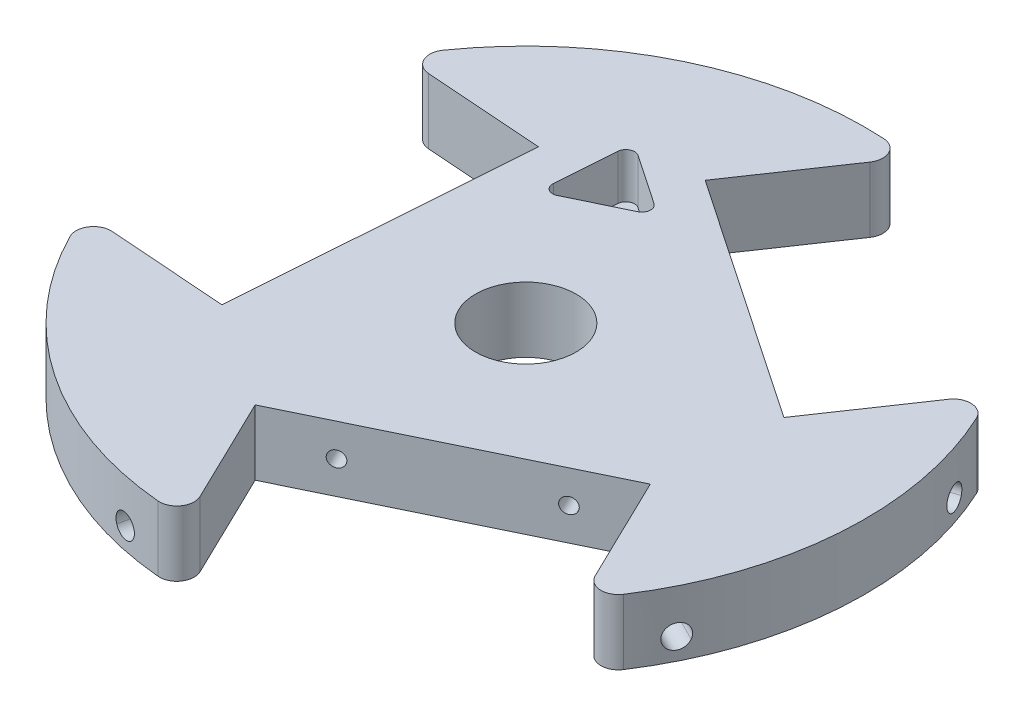
from build123d import *

# Parameters (mm, degrees)
BOSS_EXTRUDE1_DEPTH       = 9.525
F_5_8_18_TAPPED_HOLE1_D   = 14.68374
FILLET1_R                 = 2.54
F_4_40_TAPPED_HOLE1_D     = 2.2606
F_4_40_TAPPED_HOLE1_DEPTH = 6.35
F_4_40_TAPPED_HOLE1_TIP   = 0.679152758
F_4_40_TAPPED_HOLE2_D     = 2.2606
F_4_40_TAPPED_HOLE2_DEPTH = 6.35
F_4_40_TAPPED_HOLE2_TIP   = 0.679152758
F_4_40_TAPPED_HOLE3_D     = 2.2606
F_4_40_TAPPED_HOLE3_DEPTH = 6.35
F_4_40_TAPPED_HOLE3_TIP   = 0.679152758
CIRPATTERN1_COUNT         = 3
SKETCH20_R                = 3.81
CUT_EXTRUDE5_DEPTH        = 6.604


with BuildPart() as part:
    # Sketch1 → Boss-Extrude1 (new body)
    with BuildSketch(Plane(origin=(0, 0, 0), x_dir=(1, 0, 0), z_dir=(0, 1, 0))):
        with BuildLine():
            ThreePointArc((-46.024784829, -18.301368295), (-27.80965775, -40.985898012), (0, -49.53))
            Line((0, -49.53), (-9.411025641, -30.099078859))
            Line((-9.411025641, -30.099078859), (29.450816641, -11.277027577))
            Line((29.450816641, -11.277027577), (38.861842282, -30.707948718))
            ThreePointArc((38.861842282, -30.707948718), (46.787006467, -16.254135655), (49.53, 0))
            ThreePointArc((49.53, 0), (47.842306176, 12.819307304), (42.894238249, 24.765))
            Line((42.894238249, 24.765), (30.772079743, 6.899352149))
            Line((30.772079743, 6.899352149), (-4.959215959, 31.143669162))
            Line((-4.959215959, 31.143669162), (7.162942547, 49.009317013))
            ThreePointArc((7.162942547, 49.009317013), (-21.59, 44.576819088), (-42.894238249, 24.765))
            Line((-42.894238249, 24.765), (-21.361054102, 23.19972671))
            Line((-21.361054102, 23.19972671), (-24.491600681, -19.866641585))
            Line((-24.491600681, -19.866641585), (-46.024784829, -18.301368295))
        make_face()
    extrude(amount=BOSS_EXTRUDE1_DEPTH)

    # 5/8-18 Tapped Hole1 (through all)
    with Locations(Plane(origin=(0, 9.525, 0), x_dir=(1, 0, 0), z_dir=(0, 1, 0))):
        with Locations((0, 0)):
            Hole(F_5_8_18_TAPPED_HOLE1_D / 2)

    # Fillet1
    fillet1_edges = [part.edges().sort_by_distance(p)[0] for p in [
        (0, 4.7625, 49.53),
        (-46.024784829, 4.7625, 18.301368295),
        (-42.894238249, 4.7625, -24.765),
        (7.162942547, 4.7625, -49.009317013),
        (42.894238249, 4.7625, -24.765),
        (38.861842282, 4.7625, 30.707948718),
    ]]
    fillet(fillet1_edges, radius=FILLET1_R)

    # #4-40 Tapped Hole1
    with Locations(Plane(origin=(-22.926327392, 0, -1.666542563), x_dir=(-0.072499921, 0, 0.997368418), z_dir=(-0.997368418, 0, -0.072499921))):
        with Locations((-12.7, 4.7625), (12.7, 4.7625)):
            Hole(F_4_40_TAPPED_HOLE1_D / 2, depth=F_4_40_TAPPED_HOLE1_DEPTH)
            with Locations((0, 0, -(F_4_40_TAPPED_HOLE1_DEPTH + F_4_40_TAPPED_HOLE1_TIP / 2))):  # 118° drill point
                Cone(0, F_4_40_TAPPED_HOLE1_D / 2, F_4_40_TAPPED_HOLE1_TIP, mode=Mode.SUBTRACT)

    # #4-40 Tapped Hole2
    with Locations(Plane(origin=(10.0198955, 0, 20.688053218), x_dir=(0.899996347, 0, -0.435897436), z_dir=(0.435897436, 0, 0.899996347))):
        with Locations((-12.7, 4.7625), (12.7, 4.7625)):
            Hole(F_4_40_TAPPED_HOLE2_D / 2, depth=F_4_40_TAPPED_HOLE2_DEPTH)
            with Locations((0, 0, -(F_4_40_TAPPED_HOLE2_DEPTH + F_4_40_TAPPED_HOLE2_TIP / 2))):  # 118° drill point
                Cone(0, F_4_40_TAPPED_HOLE2_D / 2, F_4_40_TAPPED_HOLE2_TIP, mode=Mode.SUBTRACT)

    # #4-40 Tapped Hole3
    with Locations(Plane(origin=(12.906431892, 0, -19.021510655), x_dir=(-0.827496427, 0, -0.561470982), z_dir=(0.561470982, 0, -0.827496427))):
        with Locations((-12.7, 4.7625), (12.7, 4.7625)):
            Hole(F_4_40_TAPPED_HOLE3_D / 2, depth=F_4_40_TAPPED_HOLE3_DEPTH)
            with Locations((0, 0, -(F_4_40_TAPPED_HOLE3_DEPTH + F_4_40_TAPPED_HOLE3_TIP / 2))):  # 118° drill point
                Cone(0, F_4_40_TAPPED_HOLE3_D / 2, F_4_40_TAPPED_HOLE3_TIP, mode=Mode.SUBTRACT)

    # Sketch19 → #8-32 Tapped Hole1 (revolve, cut)
    with BuildSketch(Plane(origin=(-41.377397731, 3.151792065, 27.223737014), x_dir=(0.549641369, 0, 0.835400721), z_dir=(0, 1, 0))):
        Polygon((0, 0), (0, 7.387806461), (1.7272, 6.35), (1.7272, 0), align=None)
    f_8_32_tapped_hole1 = revolve(axis=Axis((-46.682192312, 3.151792065, 30.713959708), (0.835400721, 0, -0.549641369)), mode=Mode.SUBTRACT)

    # Mirror1: #8-32 Tapped Hole1 across plane
    add(f_8_32_tapped_hole1.mirror(Plane(origin=(0, 0, 0), x_dir=(-0.561470982, 0, 0.827496427), z_dir=(-0.827496427, 0, -0.561470982))), mode=Mode.SUBTRACT)

    # CirPattern1: #8-32 Tapped Hole1 ×3 about axis
    cirpattern1_axis = Axis((0, 9.525, 0), (0, 1, 0))
    for i in range(1, CIRPATTERN1_COUNT):
        add(f_8_32_tapped_hole1.rotate(cirpattern1_axis, i * 360 / CIRPATTERN1_COUNT), mode=Mode.SUBTRACT)

    # CirPattern1 copy 1 sketch → CirPattern1 copy 1 (revolve, cut)
    with BuildSketch(Plane(origin=(47.013518711, 3.151792065, -15.5868521), x_dir=(0.314695177, 0, 0.949192786), z_dir=(0, 1, 0))):
        Polygon((0, 0), (0, -7.387806461), (1.7272, -6.35), (1.7272, 0), align=None)
    revolve(axis=Axis((53.040892905, 3.151792065, -17.585166472), (0.949192786, 0, -0.314695177)), mode=Mode.SUBTRACT)

    # CirPattern1 copy 2 sketch → CirPattern1 copy 2 (revolve, cut)
    with BuildSketch(Plane(origin=(-37.005369239, 3.151792065, -32.921475475), x_dir=(0.664677478, 0, -0.747130411), z_dir=(0, 1, 0))):
        Polygon((0, 0), (0, -7.387806461), (1.7272, -6.35), (1.7272, 0), align=None)
    revolve(axis=Axis((-41.749647347, 3.151792065, -37.142177459), (-0.747130411, 0, -0.664677478)), mode=Mode.SUBTRACT)

    # Sketch20 → Cut-Extrude5 (cut)
    with BuildSketch(Plane(origin=(0, 9.525, 0), x_dir=(1, 0, 0), z_dir=(0, 1, 0))):
        with BuildLine():
            ThreePointArc((-9.853897655, 20.345317324), (-13.653871276, 20.621542242), (-15.314640328, 24.050528372))
            Line((-15.314640328, 24.050528372), (-15.633597147, 19.662696566))
            ThreePointArc((-15.633597147, 19.662696566), (-15.080007404, 18.519701204), (-13.813349513, 18.427626305))
            Line((-13.813349513, 18.427626305), (-9.853897655, 20.345317324))
        make_face()
        with Locations((-11.514666667, 23.774303514)):
            Circle(SKETCH20_R)
        with BuildLine():
            Line((-5.734966955, 24.456924378), (-9.375462031, 26.927064768))
            ThreePointArc((-9.375462031, 26.927064768), (-8.14817965, 25.558362136), (-7.704666667, 23.774303514))
            ThreePointArc((-7.704666667, 23.774303514), (-8.286383072, 21.750869543), (-9.853897655, 20.345317324))
            Line((-9.853897655, 20.345317324), (-5.894445359, 22.263008555))
            ThreePointArc((-5.894445359, 22.263008555), (-5.181377212, 23.313929017), (-5.734966955, 24.456924378))
        make_face()
        with BuildLine():
            ThreePointArc((-13.015957494, 29.39720542), (-14.282615385, 29.48928032), (-14.995683532, 28.438359858))
            Line((-14.995683532, 28.438359858), (-15.314640328, 24.050528372))
            ThreePointArc((-15.314640328, 24.050528372), (-13.17543572, 27.203289683), (-9.375462031, 26.927064768))
            Line((-9.375462031, 26.927064768), (-13.015957494, 29.39720542))
        make_face()
    extrude(amount=-CUT_EXTRUDE5_DEPTH, mode=Mode.SUBTRACT)


solid = part.part
